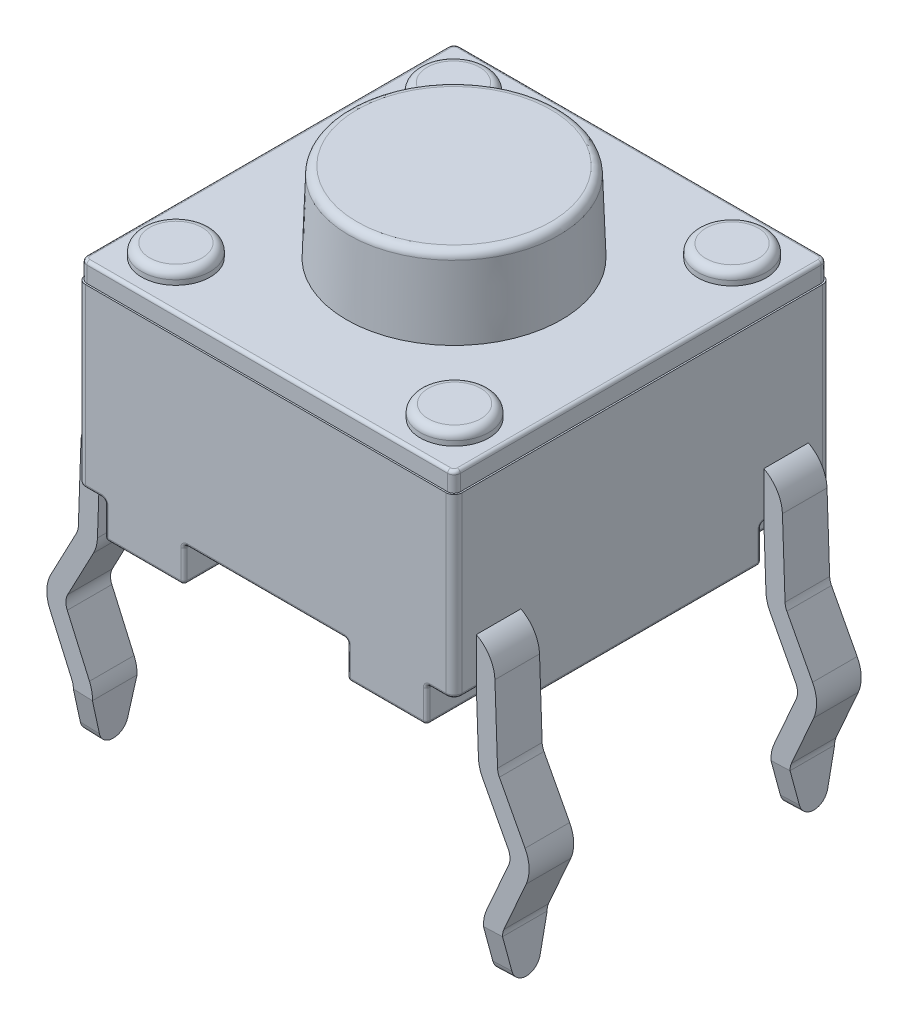
from build123d import *

# Parameters (mm, degrees)
BOSS_EXTRUDE1_START  = 0.5588
SKETCH1_W            = 6.0071
SKETCH1_H            = 6.0071
BOSS_EXTRUDE1_DEPTH  = 2.8194
FILLET1_R            = 0.127
BOSS_EXTRUDE2_DEPTH  = 0.3048
BOSS_EXTRUDE3_REACH  = 7.622
SKETCH4_R            = 0.5461
BOSS_EXTRUDE4_DEPTH  = 0.2032
SKETCH5_R            = 1.7145
BOSS_EXTRUDE5_DEPTH  = 1.27
BOSS_EXTRUDE5_TAPER  = 2
FILLET2_R            = 0.127
FILLET3_R            = 0.0508
EXTRUDE_THIN1_START  = -0.3556
EXTRUDE_THIN1_DEPTH  = 0.7112
CUT_EXTRUDE1_DEPTH   = 0.7112
MIRROR3_START        = -0.3556
MIRROR3_COPY_1_DEPTH = 0.7112
MIRROR3_COPY_2_DEPTH = 0.7112


with BuildPart() as part:
    # Sketch1 → Boss-Extrude1 (new body)
    with BuildSketch(Plane(origin=(0, 0, 0), x_dir=(1, 0, 0), z_dir=(0, 1, 0)).offset(BOSS_EXTRUDE1_START)):
        Rectangle(SKETCH1_W, SKETCH1_H)
    extrude(amount=BOSS_EXTRUDE1_DEPTH)

    # Fillet1
    fillet1_edges = [part.edges().sort_by_distance(p)[0] for p in [
        (3.00355, 1.9685, 3.00355),
        (-3.00355, 1.9685, 3.00355),
        (-3.00355, 1.9685, -3.00355),
        (3.00355, 1.9685, -3.00355),
    ]]
    fillet(fillet1_edges, radius=FILLET1_R)

    # Sketch2 → Boss-Extrude2 (add)
    with BuildSketch(Plane(origin=(0, 3.3782, 0), x_dir=(-1, 0, 0), z_dir=(0, -1, 0))):
        with BuildLine():
            Line((2.97815, -2.87655), (2.97815, 2.87655))
            ThreePointArc((2.97815, 2.87655), (2.948392049, 2.948392049), (2.87655, 2.97815))
            Line((2.87655, 2.97815), (-2.87655, 2.97815))
            ThreePointArc((-2.87655, 2.97815), (-2.948392049, 2.948392049), (-2.97815, 2.87655))
            Line((-2.97815, 2.87655), (-2.97815, -2.87655))
            ThreePointArc((-2.97815, -2.87655), (-2.948392049, -2.948392049), (-2.87655, -2.97815))
            Line((-2.87655, -2.97815), (2.87655, -2.97815))
            ThreePointArc((2.87655, -2.97815), (2.948392049, -2.948392049), (2.97815, -2.87655))
        make_face()
    extrude(amount=-BOSS_EXTRUDE2_DEPTH)

    # Sketch3 → Boss-Extrude3 (add, up to next)
    with BuildSketch(Plane(origin=(0, 0, 0), x_dir=(1, 0, 0), z_dir=(0, 1, 0)), mode=Mode.PRIVATE) as boss_extrude3_sk1:
        Polygon((-2.566197678, -3.00355), (-2.566197678, -1.89483443), (-3.00355, -1.89483443), (-3.00355, 1.89483443), (-2.566197678, 1.89483443), (-2.566197678, 3.00355), (-1.30175, 3.00355), (-1.30175, 0.560941661), (-2.441300776, 0.560941661), (-2.441300776, -0.560941661), (-1.30175, -0.560941661), (-1.30175, -3.00355), align=None)
    boss_extrude3_tool1 = extrude(boss_extrude3_sk1.sketch, amount=BOSS_EXTRUDE3_REACH, mode=Mode.PRIVATE) - part.part
    # Sketch3 → Boss-Extrude3 (add, up to next)
    with BuildSketch(Plane(origin=(0, 0, 0), x_dir=(1, 0, 0), z_dir=(0, 1, 0)), mode=Mode.PRIVATE) as boss_extrude3_sk2:
        Polygon((2.566197678, 3.00355), (2.566197678, 1.89483443), (3.00355, 1.89483443), (3.00355, -1.89483443), (2.566197678, -1.89483443), (2.566197678, -3.00355), (1.30175, -3.00355), (1.30175, -0.560941661), (2.441300776, -0.560941661), (2.441300776, 0.560941661), (1.30175, 0.560941661), (1.30175, 3.00355), align=None)
    boss_extrude3_tool2 = extrude(boss_extrude3_sk2.sketch, amount=BOSS_EXTRUDE3_REACH, mode=Mode.PRIVATE) - part.part
    add(boss_extrude3_tool1.solids().sort_by_distance((-2.503763, 0, 2.449192))[0])
    add(boss_extrude3_tool2.solids().sort_by_distance((2.503763, 0, -2.449192))[0])

    # Sketch4 → Boss-Extrude4 (add)
    with BuildSketch(Plane(origin=(0, 3.683, 0), x_dir=(1, 0, 0), z_dir=(0, 1, 0))):
        with Locations(Location((2.221694311, 2.212885437, 0), (0, 0, 90))):
            Circle(SKETCH4_R)
        with Locations(Location((-2.221694311, 2.212885437, 0), (0, 0, 90))):
            Circle(SKETCH4_R)
        with Locations(Location((-2.221694311, -2.212885437, 0), (0, 0, 90))):
            Circle(SKETCH4_R)
        with Locations(Location((2.221694311, -2.212885437, 0), (0, 0, 90))):
            Circle(SKETCH4_R)
    extrude(amount=BOSS_EXTRUDE4_DEPTH)

    # Sketch5 → Boss-Extrude5 (add)
    with BuildSketch(Plane(origin=(0, 3.683, 0), x_dir=(1, 0, 0), z_dir=(0, 1, 0))):
        Circle(SKETCH5_R)
    extrude(amount=BOSS_EXTRUDE5_DEPTH, taper=BOSS_EXTRUDE5_TAPER)

    # Fillet2
    fillet2_edges = [part.edges().sort_by_distance(p)[0] for p in [
        (2.221694311, 3.8862, -1.666785437),
        (-2.221694311, 3.8862, -1.666785437),
        (-2.221694311, 3.8862, 2.758985437),
        (2.221694311, 3.8862, 2.758985437),
        (-1.670150623, 4.953, 0),
    ]]
    fillet(fillet2_edges, radius=FILLET2_R)

    # Fillet3
    fillet3_edges = [part.edges().sort_by_distance(p)[0] for p in [
        (1.30175, 0.5588, -1.782245831),
        (1.30175, 0.2794, -3.00355),
        (1.30175, 0, -1.782245831),
        (1.871525388, 0.5588, -0.560941661),
        (1.30175, 0.2794, -0.560941661),
        (1.871525388, 0, -0.560941661),
        (2.441300776, 0.5588, 0),
        (2.441300776, 0.2794, -0.560941661),
        (2.441300776, 0, 0),
        (1.871525388, 0.5588, 0.560941661),
        (2.441300776, 0.2794, 0.560941661),
        (1.871525388, 0, 0.560941661),
        (1.30175, 0.5588, 1.782245831),
        (1.30175, 0.2794, 0.560941661),
        (1.30175, 0, 1.782245831),
        (1.30175, 0.2794, 3.00355),
        (1.933973839, 0, 3.00355),
        (2.566197678, 0.5588, 2.449192215),
        (2.566197678, 0.2794, 3.00355),
        (2.566197678, 0, 2.449192215),
        (2.784873839, 0.5588, 1.89483443),
        (2.566197678, 0.2794, 1.89483443),
        (2.784873839, 0, 1.89483443),
        (3.00355, 0.2794, 1.89483443),
        (3.00355, 0, 0),
        (2.784873839, 0.5588, -1.89483443),
        (3.00355, 0.2794, -1.89483443),
        (2.784873839, 0, -1.89483443),
        (2.566197678, 0.2794, -3.00355),
        (1.933973839, 0, -3.00355),
        (2.566197678, 0.5588, -2.449192215),
        (2.566197678, 0.2794, -1.89483443),
        (2.566197678, 0, -2.449192215),
        (-2.721373839, 0.5588, 3.00355),
        (3.00355, 0.5588, 2.385692215),
        (-3.00355, 0.5588, -2.385692215),
        (2.721373839, 0.5588, -3.00355),
        (2.966352561, 0.5588, 2.966352561),
        (2.966352561, 0.5588, -2.966352561),
        (-2.966352561, 0.5588, -2.966352561),
        (-2.966352561, 0.5588, 2.966352561),
        (-2.948392049, 3.683, 2.948392049),
        (0, 3.683, 2.97815),
        (2.948392049, 3.683, 2.948392049),
        (2.97815, 3.683, 0),
        (2.948392049, 3.683, -2.948392049),
        (0, 3.683, -2.97815),
        (-2.948392049, 3.683, -2.948392049),
        (-2.97815, 3.683, 0),
        (0, 0.5588, 3.00355),
        (-3.00355, 0.5588, 2.385692215),
        (-2.721373839, 0.5588, -3.00355),
        (-1.30175, 0.5588, 1.782245831),
        (-1.30175, 0.2794, 3.00355),
        (-1.30175, 0, 1.782245831),
        (-1.871525388, 0.5588, 0.560941661),
        (-1.30175, 0.2794, 0.560941661),
        (-1.871525388, 0, 0.560941661),
        (-2.441300776, 0.5588, 0),
        (-2.441300776, 0.2794, 0.560941661),
        (-2.441300776, 0, 0),
        (-1.871525388, 0.5588, -0.560941661),
        (-2.441300776, 0.2794, -0.560941661),
        (-1.871525388, 0, -0.560941661),
        (-1.30175, 0.5588, -1.782245831),
        (-1.30175, 0.2794, -0.560941661),
        (-1.30175, 0, -1.782245831),
        (-1.30175, 0.2794, -3.00355),
        (-1.933973839, 0, -3.00355),
        (-2.566197678, 0.5588, -2.449192215),
        (-2.566197678, 0.2794, -3.00355),
        (-2.566197678, 0, -2.449192215),
        (-2.784873839, 0.5588, -1.89483443),
        (-2.566197678, 0.2794, -1.89483443),
        (-2.784873839, 0, -1.89483443),
        (-3.00355, 0.2794, -1.89483443),
        (-3.00355, 0, 0),
        (-2.784873839, 0.5588, 1.89483443),
        (-3.00355, 0.2794, 1.89483443),
        (-2.784873839, 0, 1.89483443),
        (-2.566197678, 0.2794, 3.00355),
        (-1.933973839, 0, 3.00355),
        (-2.566197678, 0.5588, 2.449192215),
        (-2.566197678, 0.2794, 1.89483443),
        (-2.566197678, 0, 2.449192215),
        (0, 0.5588, -3.00355),
        (3.00355, 0.5588, -2.385692215),
        (2.721373839, 0.5588, 3.00355),
    ]]
    fillet(fillet3_edges, radius=FILLET3_R)

    # Sketch6 → Extrude-Thin1 (add)
    with BuildSketch(Plane.XY.offset(3.00355).offset(EXTRUDE_THIN1_START)):
        with BuildLine():
            Line((-2.526489479, 1.064092226), (-2.74199854, 1.064092226))
            ThreePointArc((-2.74199854, 1.064092226), (-2.918441767, 0.992804535), (-2.995843811, 0.818956698))
            Line((-2.995843811, 0.818956698), (-3.03780929, -0.382777412))
            ThreePointArc((-3.03780929, -0.382777412), (-3.056264298, -0.506985303), (-3.10198813, -0.623936226))
            Line((-3.10198813, -0.623936226), (-3.511410555, -1.400308198))
            ThreePointArc((-3.511410555, -1.400308198), (-3.540582755, -1.509925841), (-3.519128157, -1.62131141))
            Line((-3.519128157, -1.62131141), (-3.164860036, -2.424352043))
            ThreePointArc((-3.164860036, -2.424352043), (-3.127405669, -2.544207613), (-3.117659921, -2.669400296))
            Line((-3.117659921, -2.669400296), (-3.142411752, -3.3782))
            Line((-3.142411752, -3.3782), (-3.447026076, -3.367562633))
            Line((-3.447026076, -3.367562633), (-3.422274245, -2.658762929))
            ThreePointArc((-3.422274245, -2.658762929), (-3.42670413, -2.601857165), (-3.443728843, -2.54737736))
            Line((-3.443728843, -2.54737736), (-3.797996964, -1.744336727))
            ThreePointArc((-3.797996964, -1.744336727), (-3.845197079, -1.499288474), (-3.781018239, -1.25812966))
            Line((-3.781018239, -1.25812966), (-3.371595814, -0.481757688))
            ThreePointArc((-3.371595814, -0.481757688), (-3.350812254, -0.428598178), (-3.342423614, -0.372140046))
            Line((-3.342423614, -0.372140046), (-3.300458135, 0.829594065))
            ThreePointArc((-3.300458135, 0.829594065), (-3.130173638, 1.212059307), (-2.74199854, 1.368892226))
            Line((-2.74199854, 1.368892226), (-2.526489479, 1.368892226))
            Line((-2.526489479, 1.368892226), (-2.526489479, 1.064092226))
        make_face()
    extrude_thin1 = extrude(amount=-EXTRUDE_THIN1_DEPTH)

    # Sketch9 → Cut-Extrude1 (cut)
    with BuildSketch(Plane(origin=(-3.325373038, 0.116124585, 0), x_dir=(0, 0, 1), z_dir=(-0.9993908270190955, 0.034899496702504834, 0))):
        with BuildLine():
            Line((2.64795, -3.48581068), (2.64795, -2.776578932))
            Line((2.64795, -2.776578932), (2.517535772, -3.30911696))
            ThreePointArc((2.517535772, -3.30911696), (2.435466476, -3.436364343), (2.29235, -3.48581068))
            Line((2.29235, -3.48581068), (2.64795, -3.48581068))
        make_face()
        with BuildLine():
            Line((1.93675, -3.48581068), (2.29235, -3.48581068))
            ThreePointArc((2.29235, -3.48581068), (2.149233524, -3.436364343), (2.067164228, -3.30911696))
            Line((2.067164228, -3.30911696), (1.93675, -2.776578932))
            Line((1.93675, -2.776578932), (1.93675, -3.48581068))
        make_face()
    cut_extrude1 = extrude(amount=-CUT_EXTRUDE1_DEPTH, mode=Mode.SUBTRACT)

    # Mirror1: Extrude-Thin1, Cut-Extrude1 across plane
    add(extrude_thin1.mirror(Plane.XY))
    add(cut_extrude1.mirror(Plane.XY), mode=Mode.SUBTRACT)

    # Mirror3: Extrude-Thin1, Cut-Extrude1 across plane
    add(extrude_thin1.mirror(Plane(origin=(0, 0, 0), x_dir=(0, 0, 1), z_dir=(1, 0, 0))))
    add(cut_extrude1.mirror(Plane(origin=(0, 0, 0), x_dir=(0, 0, 1), z_dir=(1, 0, 0))), mode=Mode.SUBTRACT)

    # Mirror3 copy 1 sketch → Mirror3 copy 1 (add)
    with BuildSketch(Plane(origin=(0, 0, -3.00355), x_dir=(-1, 0, 0), z_dir=(0, 0, -1)).offset(MIRROR3_START)):
        with BuildLine():
            Line((-2.526489479, 1.064092226), (-2.74199854, 1.064092226))
            ThreePointArc((-2.74199854, 1.064092226), (-2.918441767, 0.992804535), (-2.995843811, 0.818956698))
            Line((-2.995843811, 0.818956698), (-3.03780929, -0.382777412))
            ThreePointArc((-3.03780929, -0.382777412), (-3.056264298, -0.506985303), (-3.10198813, -0.623936226))
            Line((-3.10198813, -0.623936226), (-3.511410555, -1.400308198))
            ThreePointArc((-3.511410555, -1.400308198), (-3.540582755, -1.509925841), (-3.519128157, -1.62131141))
            Line((-3.519128157, -1.62131141), (-3.164860036, -2.424352043))
            ThreePointArc((-3.164860036, -2.424352043), (-3.127405669, -2.544207613), (-3.117659921, -2.669400296))
            Line((-3.117659921, -2.669400296), (-3.142411752, -3.3782))
            Line((-3.142411752, -3.3782), (-3.447026076, -3.367562633))
            Line((-3.447026076, -3.367562633), (-3.422274245, -2.658762929))
            ThreePointArc((-3.422274245, -2.658762929), (-3.42670413, -2.601857165), (-3.443728843, -2.54737736))
            Line((-3.443728843, -2.54737736), (-3.797996964, -1.744336727))
            ThreePointArc((-3.797996964, -1.744336727), (-3.845197079, -1.499288474), (-3.781018239, -1.25812966))
            Line((-3.781018239, -1.25812966), (-3.371595814, -0.481757688))
            ThreePointArc((-3.371595814, -0.481757688), (-3.350812254, -0.428598178), (-3.342423614, -0.372140046))
            Line((-3.342423614, -0.372140046), (-3.300458135, 0.829594065))
            ThreePointArc((-3.300458135, 0.829594065), (-3.130173638, 1.212059307), (-2.74199854, 1.368892226))
            Line((-2.74199854, 1.368892226), (-2.526489479, 1.368892226))
            Line((-2.526489479, 1.368892226), (-2.526489479, 1.064092226))
        make_face()
    extrude(amount=-MIRROR3_COPY_1_DEPTH)

    # Mirror3 copy 2 sketch → Mirror3 copy 2 (cut)
    with BuildSketch(Plane(origin=(3.325373038, 0.116124585, 0), x_dir=(0, 0, -1), z_dir=(0.9993908270190955, 0.034899496702504834, 0))):
        with BuildLine():
            Line((2.64795, -3.48581068), (2.64795, -2.776578932))
            Line((2.64795, -2.776578932), (2.517535772, -3.30911696))
            ThreePointArc((2.517535772, -3.30911696), (2.435466476, -3.436364343), (2.29235, -3.48581068))
            Line((2.29235, -3.48581068), (2.64795, -3.48581068))
        make_face()
        with BuildLine():
            Line((1.93675, -3.48581068), (2.29235, -3.48581068))
            ThreePointArc((2.29235, -3.48581068), (2.149233524, -3.436364343), (2.067164228, -3.30911696))
            Line((2.067164228, -3.30911696), (1.93675, -2.776578932))
            Line((1.93675, -2.776578932), (1.93675, -3.48581068))
        make_face()
    extrude(amount=-MIRROR3_COPY_2_DEPTH, mode=Mode.SUBTRACT)


solid = part.part
